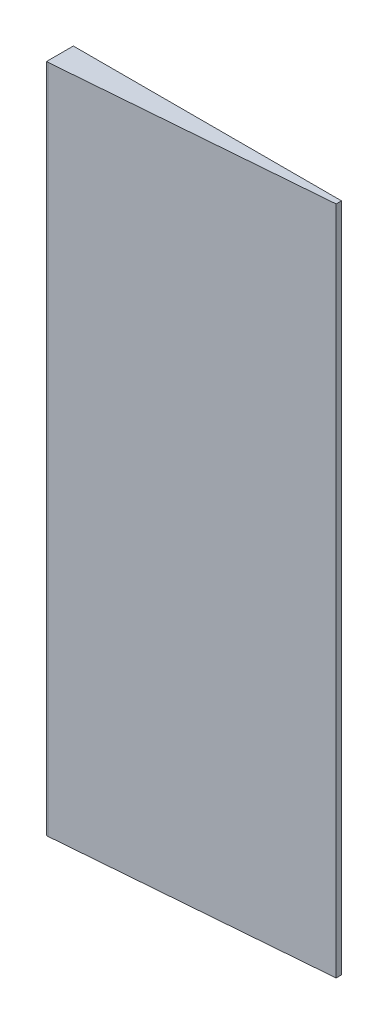
from build123d import *

# Parameters (mm, degrees)
SKETCH1_W           = 10
SKETCH1_H           = 25
BOSS_EXTRUDE1_DEPTH = 1
CHAMFER1_SIZE       = 0.8
CHAMFER1_SIZE2      = 9.943064816


with BuildPart() as part:
    # Sketch1 → Boss-Extrude1 (new body)
    with BuildSketch(Plane.XY):
        with Locations((-5, 12.5)):
            Rectangle(SKETCH1_W, SKETCH1_H)
    extrude(amount=BOSS_EXTRUDE1_DEPTH)

    # Chamfer1
    chamfer1_edges = [part.edges().sort_by_distance(p)[0] for p in [
        (0, 12.5, 1),
    ]]
    chamfer1_side = [part.faces().sort_by_distance(p)[0] for p in [
        (0, 12.5, 0.5),
    ]]
    chamfer(chamfer1_edges, length=CHAMFER1_SIZE, length2=CHAMFER1_SIZE2, reference=chamfer1_side[0])


solid = part.part
